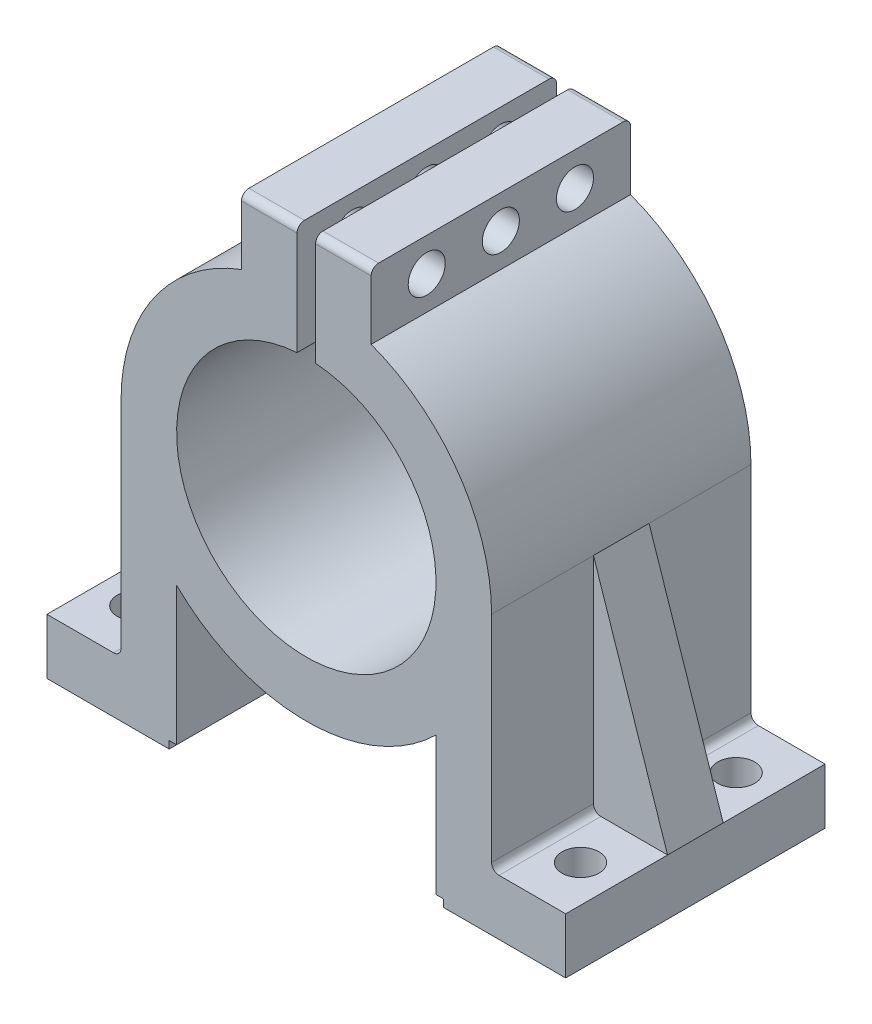
from build123d import *

# Parameters (mm, degrees)
SALIENTE_EXTRUIR1_DEPTH      = 7
SALIENTE_EXTRUIR1_DEPTH_BACK = 7
REDONDEO1_R                  = 0.4
SALIENTE_EXTRUIR2_DEPTH      = 1.5
SALIENTE_EXTRUIR2_DEPTH_BACK = 1.5
CORTAR_EXTRUIR1_REACH        = 31.468
CROQUIS4_R                   = 1
CROQUIS5_R                   = 1
CORTAR_EXTRUIR2_DEPTH        = 8.5


with BuildPart() as part:
    # Croquis2 → Saliente-Extruir1 (new, two sides: drawn at the far end of the back side and taken through both)
    with BuildSketch(Plane.XY.offset(-SALIENTE_EXTRUIR1_DEPTH_BACK)):
        with BuildLine():
            Line((-10, 0), (-10, -11.6))
            ThreePointArc((-10, -11.6), (-10.117157288, -11.882842712), (-10.4, -12))
            Line((-10.4, -12), (-14, -12))
            Line((-14, -12), (-14, -15))
            Line((-14, -15), (-7.4, -15))
            Line((-7.4, -15), (-7.4, -14.6))
            Line((-7.4, -14.6), (-7, -14.6))
            Line((-7, -14.6), (-7, -7.141428429))
            ThreePointArc((-7, -7.141428429), (0, -10), (7, -7.141428429))
            Line((7, -7.141428429), (7, -14.6))
            Line((7, -14.6), (7.4, -14.6))
            Line((7.4, -14.6), (7.4, -15))
            Line((7.4, -15), (14, -15))
            Line((14, -15), (14, -12))
            Line((14, -12), (10.4, -12))
            ThreePointArc((10.4, -12), (10.117157288, -11.882842712), (10, -11.6))
            Line((10, -11.6), (10, 0))
            ThreePointArc((10, 0), (8.215838363, 5.700877125), (3.5, 9.367496998))
            Line((3.5, 9.367496998), (3.5, 12.967496998))
            Line((3.5, 12.967496998), (0.5, 12.967496998))
            Line((0.5, 12.967496998), (0.5, 9.987492178))
            Line((0.5, 9.987492178), (0.5, 6.982120022))
            ThreePointArc((0.5, 6.982120022), (0, -7), (-0.5, 6.982120022))
            Line((-0.5, 6.982120022), (-0.5, 9.987492178))
            Line((-0.5, 9.987492178), (-0.5, 12.967496998))
            Line((-0.5, 12.967496998), (-3.5, 12.967496998))
            Line((-3.5, 12.967496998), (-3.5, 9.367496998))
            ThreePointArc((-3.5, 9.367496998), (-8.215838363, 5.700877125), (-10, 0))
        make_face()
    extrude(amount=SALIENTE_EXTRUIR1_DEPTH + SALIENTE_EXTRUIR1_DEPTH_BACK)

    # Redondeo1
    redondeo1_edges = [part.edges().sort_by_distance(p)[0] for p in [
        (-2, 12.967496998, 7),
        (-2, 12.967496998, -7),
        (2, 12.967496998, -7),
        (2, 12.967496998, 7),
    ]]
    fillet(redondeo1_edges, radius=REDONDEO1_R)

    # Croquis3 → Saliente-Extruir2 (add, two sides: drawn at the far end of the back side and taken through both)
    with BuildSketch(Plane.XY.offset(-SALIENTE_EXTRUIR2_DEPTH_BACK)):
        Polygon((10, 0), (14, -12), (10, -12), align=None)
        Polygon((-10, -12), (-14, -12), (-10, 0), align=None)
    extrude(amount=SALIENTE_EXTRUIR2_DEPTH + SALIENTE_EXTRUIR2_DEPTH_BACK)

    # Croquis4 → Cortar-Extruir1 (cut, up to next)
    with BuildSketch(Plane(origin=(0, -12, 0), x_dir=(1, 0, 0), z_dir=(0, 1, 0)), mode=Mode.PRIVATE) as cortar_extruir1_sk1:
        with Locations((12, -4.2)):
            Circle(CROQUIS4_R)
    cortar_extruir1_tool1 = extrude(cortar_extruir1_sk1.sketch, amount=-CORTAR_EXTRUIR1_REACH, mode=Mode.PRIVATE) & part.part
    # Croquis4 → Cortar-Extruir1 (cut, up to next)
    with BuildSketch(Plane(origin=(0, -12, 0), x_dir=(1, 0, 0), z_dir=(0, 1, 0)), mode=Mode.PRIVATE) as cortar_extruir1_sk2:
        with Locations((12, 4.2)):
            Circle(CROQUIS4_R)
    cortar_extruir1_tool2 = extrude(cortar_extruir1_sk2.sketch, amount=-CORTAR_EXTRUIR1_REACH, mode=Mode.PRIVATE) & part.part
    # Croquis4 → Cortar-Extruir1 (cut, up to next)
    with BuildSketch(Plane(origin=(0, -12, 0), x_dir=(1, 0, 0), z_dir=(0, 1, 0)), mode=Mode.PRIVATE) as cortar_extruir1_sk3:
        with Locations((-12, 4.2)):
            Circle(CROQUIS4_R)
    cortar_extruir1_tool3 = extrude(cortar_extruir1_sk3.sketch, amount=-CORTAR_EXTRUIR1_REACH, mode=Mode.PRIVATE) & part.part
    # Croquis4 → Cortar-Extruir1 (cut, up to next)
    with BuildSketch(Plane(origin=(0, -12, 0), x_dir=(1, 0, 0), z_dir=(0, 1, 0)), mode=Mode.PRIVATE) as cortar_extruir1_sk4:
        with Locations((-12, -4.2)):
            Circle(CROQUIS4_R)
    cortar_extruir1_tool4 = extrude(cortar_extruir1_sk4.sketch, amount=-CORTAR_EXTRUIR1_REACH, mode=Mode.PRIVATE) & part.part
    add(cortar_extruir1_tool1.solids().sort_by_distance((12, -12, 4.2))[0], mode=Mode.SUBTRACT)
    add(cortar_extruir1_tool2.solids().sort_by_distance((12, -12, -4.2))[0], mode=Mode.SUBTRACT)
    add(cortar_extruir1_tool3.solids().sort_by_distance((-12, -12, -4.2))[0], mode=Mode.SUBTRACT)
    add(cortar_extruir1_tool4.solids().sort_by_distance((-12, -12, 4.2))[0], mode=Mode.SUBTRACT)

    # Croquis5 → Cortar-Extruir2 (cut)
    with BuildSketch(Plane(origin=(3.5, 0, 0), x_dir=(0, 0, -1), z_dir=(1, 0, 0))):
        with Locations((0, 11.167496998)):
            Circle(CROQUIS5_R)
        with Locations((4, 11.167496998)):
            Circle(CROQUIS5_R)
        with Locations((-4, 11.167496998)):
            Circle(CROQUIS5_R)
    extrude(amount=-CORTAR_EXTRUIR2_DEPTH, mode=Mode.SUBTRACT)


solid = part.part
